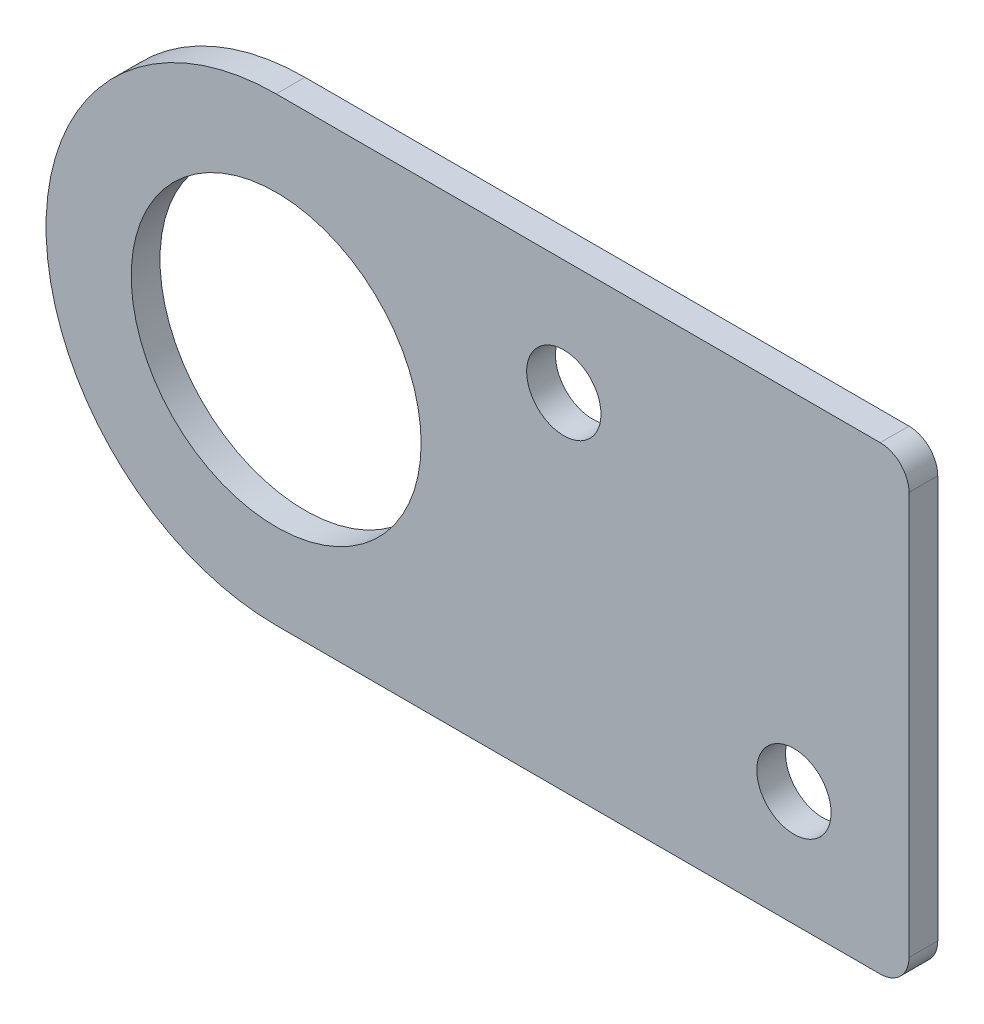
from build123d import *

# Parameters (mm, degrees)
SKETCH1_R           = 8
SKETCH1_R_2         = 2.05
BOSS_EXTRUDE1_DEPTH = 1.5875
FILLET1_R           = 1.5875


with BuildPart() as part:
    # Sketch1 → Boss-Extrude1 (new body)
    with BuildSketch(Plane.XY):
        with BuildLine():
            ThreePointArc((-165.1, 8.400260413), (-169.399739587, 11.575260413), (-174.625, 12.7))
            ThreePointArc((-174.625, 12.7), (-187.325, 0), (-174.625, -12.7))
            ThreePointArc((-174.625, -12.7), (-169.399739587, -11.575260413), (-165.1, -8.400260413))
            Line((-165.1, -8.400260413), (-165.1, 8.400260413))
        make_face()
        with Locations((-174.625, 0)):
            Circle(SKETCH1_R, mode=Mode.SUBTRACT)
        with BuildLine():
            Line((-165.1, 12.7), (-174.625, 12.7))
            ThreePointArc((-174.625, 12.7), (-169.399739587, 11.575260413), (-165.1, 8.400260413))
            Line((-165.1, 8.400260413), (-165.1, 12.7))
        make_face()
        with BuildLine():
            Line((-139.7, 12.7), (-165.1, 12.7))
            Line((-165.1, 12.7), (-165.1, 8.400260413))
            ThreePointArc((-165.1, 8.400260413), (-162.745237797, 4.490128061), (-161.925, 0))
            ThreePointArc((-161.925, 0), (-162.745237797, -4.490128061), (-165.1, -8.400260413))
            Line((-165.1, -8.400260413), (-165.1, -12.7))
            Line((-165.1, -12.7), (-139.7, -12.7))
            Line((-139.7, -12.7), (-139.7, 12.7))
        make_face()
        with Locations((-146.05, -6.35)):
            Circle(SKETCH1_R_2, mode=Mode.SUBTRACT)
        with Locations((-158.75, 6.35)):
            Circle(SKETCH1_R_2, mode=Mode.SUBTRACT)
        with BuildLine():
            ThreePointArc((-161.925, 0), (-162.745237797, 4.490128061), (-165.1, 8.400260413))
            Line((-165.1, 8.400260413), (-165.1, -8.400260413))
            ThreePointArc((-165.1, -8.400260413), (-162.745237797, -4.490128061), (-161.925, 0))
        make_face()
        with BuildLine():
            ThreePointArc((-165.1, -8.400260413), (-169.399739587, -11.575260413), (-174.625, -12.7))
            Line((-174.625, -12.7), (-165.1, -12.7))
            Line((-165.1, -12.7), (-165.1, -8.400260413))
        make_face()
    extrude(amount=BOSS_EXTRUDE1_DEPTH)

    # Fillet1
    fillet1_edges = [part.edges().sort_by_distance(p)[0] for p in [
        (-139.7, 12.7, 0.79375),
        (-139.7, -12.7, 0.79375),
    ]]
    fillet(fillet1_edges, radius=FILLET1_R)


solid = part.part
